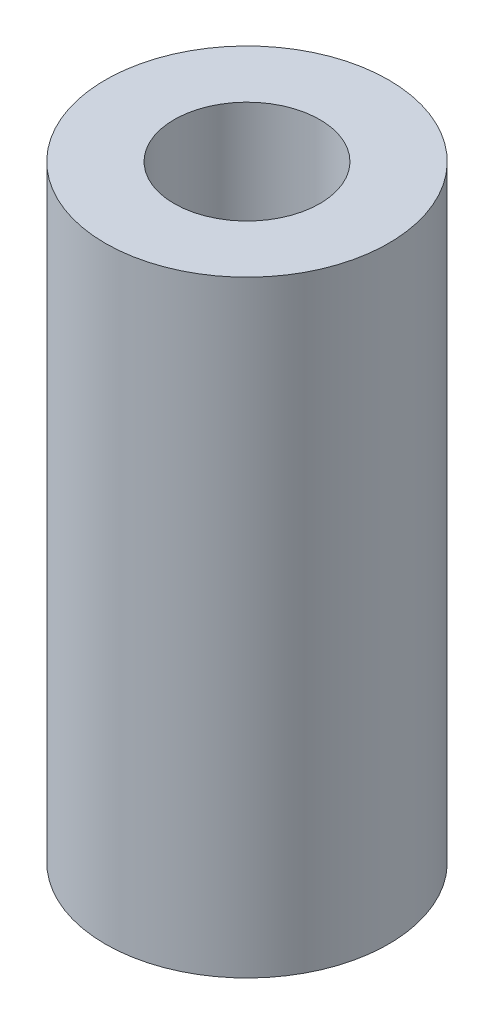
from build123d import *

# Parameters (mm, degrees)
SKETCH1_R           = 3.5
SKETCH1_R_2         = 1.8
BOSS_EXTRUDE1_DEPTH = 7.5


with BuildPart() as part:
    # Sketch1 → Boss-Extrude1 (new body, symmetric)
    with BuildSketch(Plane(origin=(0, 0, 0), x_dir=(1, 0, 0), z_dir=(0, 1, 0))):
        Circle(SKETCH1_R)
        Circle(SKETCH1_R_2, mode=Mode.SUBTRACT)
    extrude(amount=BOSS_EXTRUDE1_DEPTH, both=True)


solid = part.part
